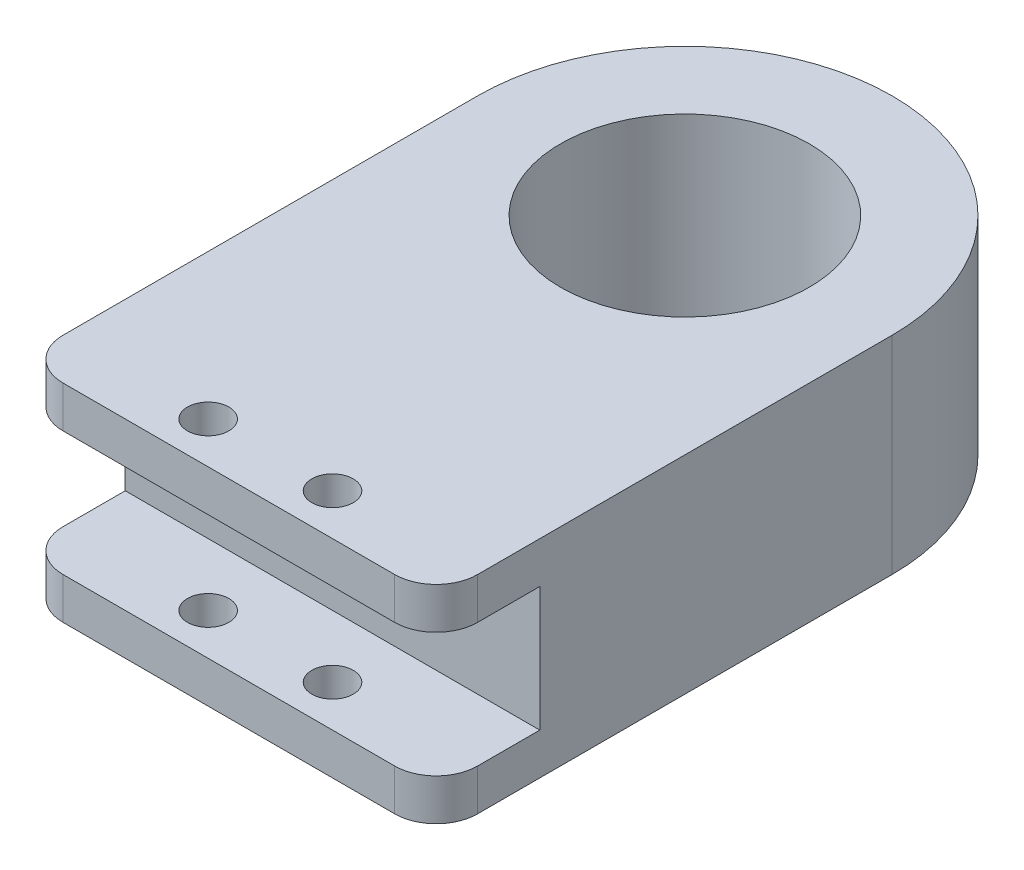
from build123d import *

# Parameters (mm, degrees)
SKETCH1_R           = 30
SKETCH1_R_2         = 5
BOSS_EXTRUDE1_DEPTH = 50
SKETCH2_W           = 25
SKETCH2_H           = 30
CUT_EXTRUDE1_DEPTH  = 101


with BuildPart() as part:
    # Sketch1 → Boss-Extrude1 (new body)
    with BuildSketch(Plane(origin=(0, 0, 0), x_dir=(1, 0, 0), z_dir=(0, 1, 0))):
        with BuildLine():
            Line((-50, -60), (-50, 0))
            ThreePointArc((-50, 0), (0, 50), (50, 0))
            Line((50, 0), (50, -60))
            Line((50, -60), (50, -100))
            ThreePointArc((50, -100), (47.071067812, -107.071067812), (40, -110))
            Line((40, -110), (-40, -110))
            ThreePointArc((-40, -110), (-47.071067812, -107.071067812), (-50, -100))
            Line((-50, -100), (-50, -60))
        make_face()
        Circle(SKETCH1_R, mode=Mode.SUBTRACT)
        with Locations((-15, -100)):
            Circle(SKETCH1_R_2, mode=Mode.SUBTRACT)
        with Locations((15, -100)):
            Circle(SKETCH1_R_2, mode=Mode.SUBTRACT)
    extrude(amount=BOSS_EXTRUDE1_DEPTH)

    # Sketch2 → Cut-Extrude1 (cut, through all)
    with BuildSketch(Plane(origin=(50, 0, 0), x_dir=(0, 0, -1), z_dir=(1, 0, 0))):
        with Locations((-97.5, 25)):
            Rectangle(SKETCH2_W, SKETCH2_H)
    extrude(amount=-CUT_EXTRUDE1_DEPTH, mode=Mode.SUBTRACT)


solid = part.part
